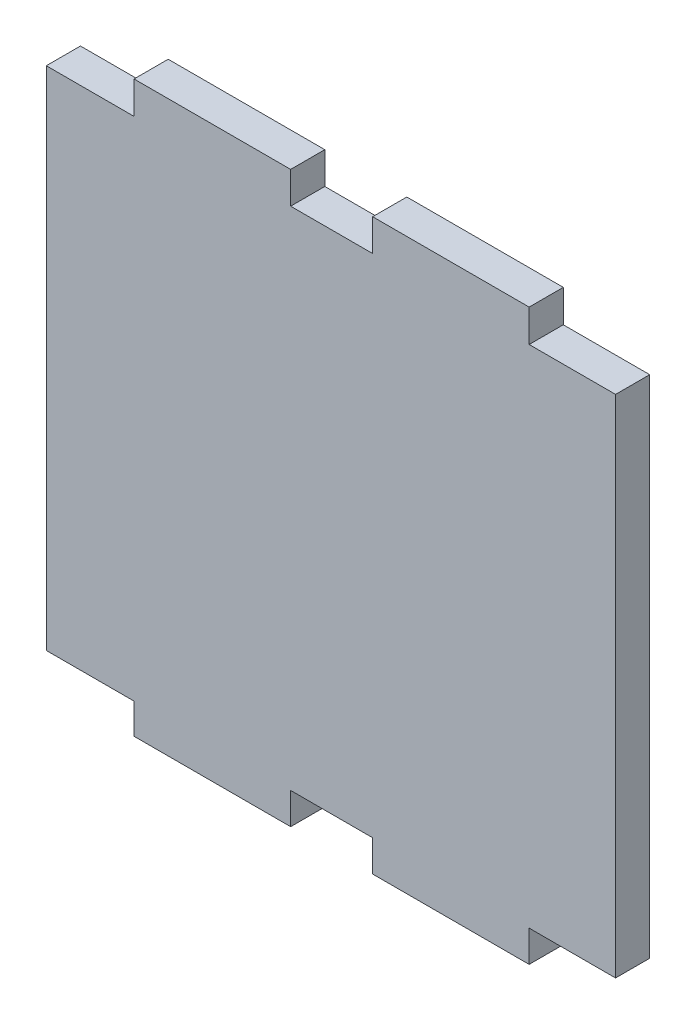
from build123d import *

# Parameters (mm, degrees)
SKETCH2_W           = 200
SKETCH2_H           = 200
BOSS_EXTRUDE1_DEPTH = 12
SKETCH3_W           = 30.360004712
SKETCH3_H           = 11.388437722
SKETCH3_W_2         = 30.831307096
SKETCH3_H_2         = 11.388437723
SKETCH3_H_3         = 11.04380164
SKETCH3_W_3         = 28.808688193
SKETCH3_H_4         = 11.201915466
SKETCH3_H_5         = 10.699165557
CUT_EXTRUDE4_DEPTH  = 13


with BuildPart() as part:
    # Sketch2 → Boss-Extrude1 (new body)
    with BuildSketch(Plane.XY):
        with Locations((100, 100)):
            Rectangle(SKETCH2_W, SKETCH2_H)
    extrude(amount=BOSS_EXTRUDE1_DEPTH)

    # Sketch3 → Cut-Extrude4 (cut, through all)
    with BuildSketch(Plane(origin=(0, 0, 0), x_dir=(-1, 0, 0), z_dir=(0, 0, -1))):
        with Locations((-184.819997644, 194.305781139)):
            Rectangle(SKETCH3_W, SKETCH3_H)
        with Locations((-15.415653548, 194.305781139)):
            Rectangle(SKETCH3_W_2, SKETCH3_H_2)
        with Locations((-184.819997644, 5.52190082)):
            Rectangle(SKETCH3_W, SKETCH3_H_3)
        with Locations((-100.2551028, 194.399042267)):
            Rectangle(SKETCH3_W_3, SKETCH3_H_4)
        with Locations((-15.415653548, 5.349582779)):
            Rectangle(SKETCH3_W_2, SKETCH3_H_5)
        with Locations((-100.2551028, 5.52190082)):
            Rectangle(SKETCH3_W_3, SKETCH3_H_3)
    extrude(amount=-CUT_EXTRUDE4_DEPTH, mode=Mode.SUBTRACT)


solid = part.part
